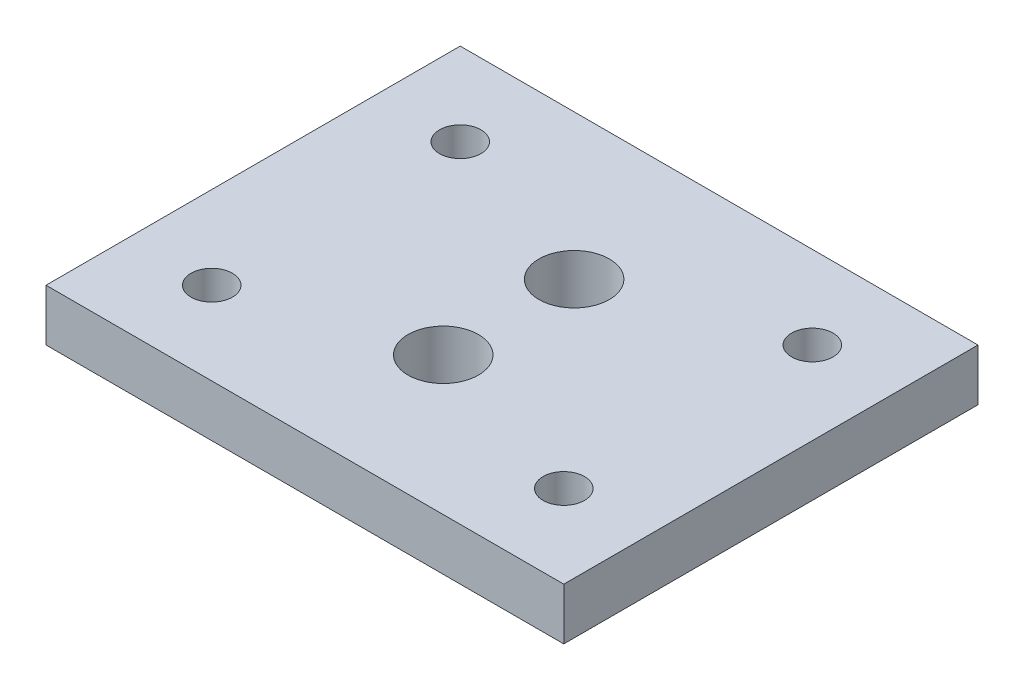
from build123d import *

# Parameters (mm, degrees)
SKETCH1_W        = 31.75
SKETCH1_H        = 25.4
SKETCH1_R        = 1.27
EXTRUSION1_DEPTH = 3.175
SKETCH2_R        = 2.159
EXTRUSION2_DEPTH = 4.175


with BuildPart() as part:
    # Sketch1 → Extrusion1 (new body)
    with BuildSketch(Plane(origin=(0, 0, 0), x_dir=(-1, 0, 0), z_dir=(0, 1, 0))):
        with Locations((15.875, -12.7)):
            Rectangle(SKETCH1_W, SKETCH1_H)
        with Locations((26.67, -5.08)):
            Circle(SKETCH1_R, mode=Mode.SUBTRACT)
        with Locations((26.67, -20.32)):
            Circle(SKETCH1_R, mode=Mode.SUBTRACT)
        with Locations((5.08, -20.32)):
            Circle(SKETCH1_R, mode=Mode.SUBTRACT)
        with Locations((5.08, -5.08)):
            Circle(SKETCH1_R, mode=Mode.SUBTRACT)
    extrude(amount=EXTRUSION1_DEPTH)

    # Sketch2 → Extrusion2 (cut, through all)
    with BuildSketch(Plane(origin=(0, 3.175, 0), x_dir=(-1, 0, 0), z_dir=(0, 1, 0))):
        with Locations((15.875, -8.4836)):
            Circle(SKETCH2_R)
        with Locations((15.875, -16.51)):
            Circle(SKETCH2_R)
    extrude(amount=-EXTRUSION2_DEPTH, mode=Mode.SUBTRACT)


solid = part.part
